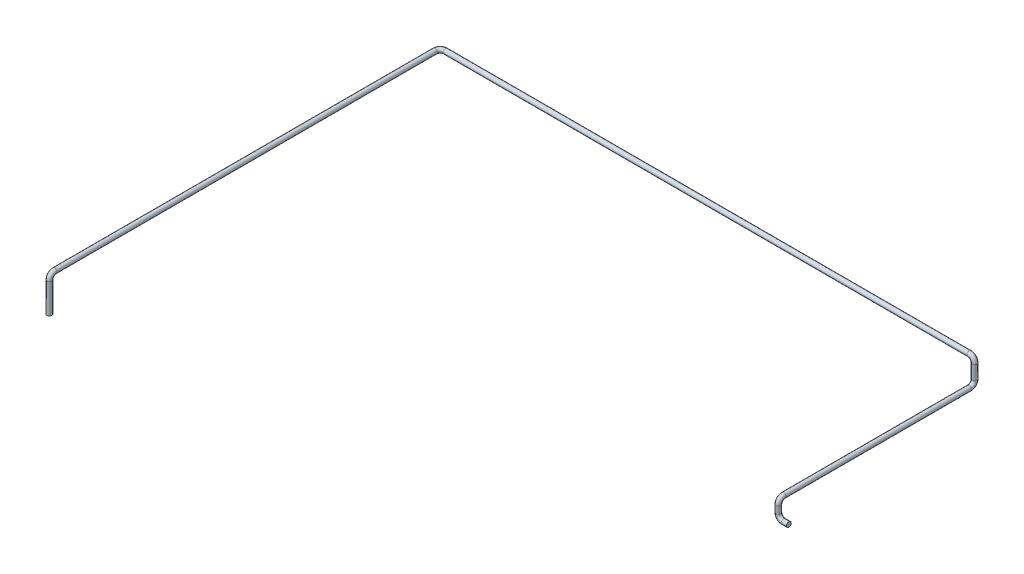
from build123d import *

# Parameters (mm, degrees)
CROQUIS1_R = 13.7


with BuildPart() as part:
    # Barrer1: sweep along a curve in space
    with BuildLine() as barrer1_path:
        Line((0, 0, 0), (-30, 0, 0))
        ThreePointArc((-30, 0, 0), (-51.213203436, 8.786796564, 0), (-60, 30, 0))
        Line((-60, 30, 0), (-60, 70, 0))
        ThreePointArc((-60, 70, 0), (-60, 91.213203436, -8.786796564), (-60, 100, -30))
        Line((-60, 100, -30), (-60, 100, -1090))
        ThreePointArc((-60, 130, -1120), (-60, 108.786796564, -1111.213203436), (-60, 100, -1090))
        Line((-60, 130, -1120), (-60, 210, -1120))
        ThreePointArc((-60, 210, -1120), (-68.786796564, 231.213203436, -1120), (-90, 240, -1120))
        Line((-90, 240, -1120), (-3080, 240, -1120))
        ThreePointArc((-3080, 240, -1120), (-3101.213203436, 240, -1111.213203436), (-3110, 240, -1090))
        Line((-3110, 240, -1090), (-3110, 240, 1080))
        ThreePointArc((-3110, 240, 1080), (-3110, 231.213203436, 1101.213203436), (-3110, 210, 1110))
        Line((-3110, 210, 1110), (-3110, 40, 1110))
    # Croquis1 → Barrer1 (sweep)
    with BuildSketch(Plane(origin=(0, 0, 0), x_dir=(0, 0, -1), z_dir=(1, 0, 0))):
        Circle(CROQUIS1_R)
    sweep(path=barrer1_path.line)


solid = part.part
